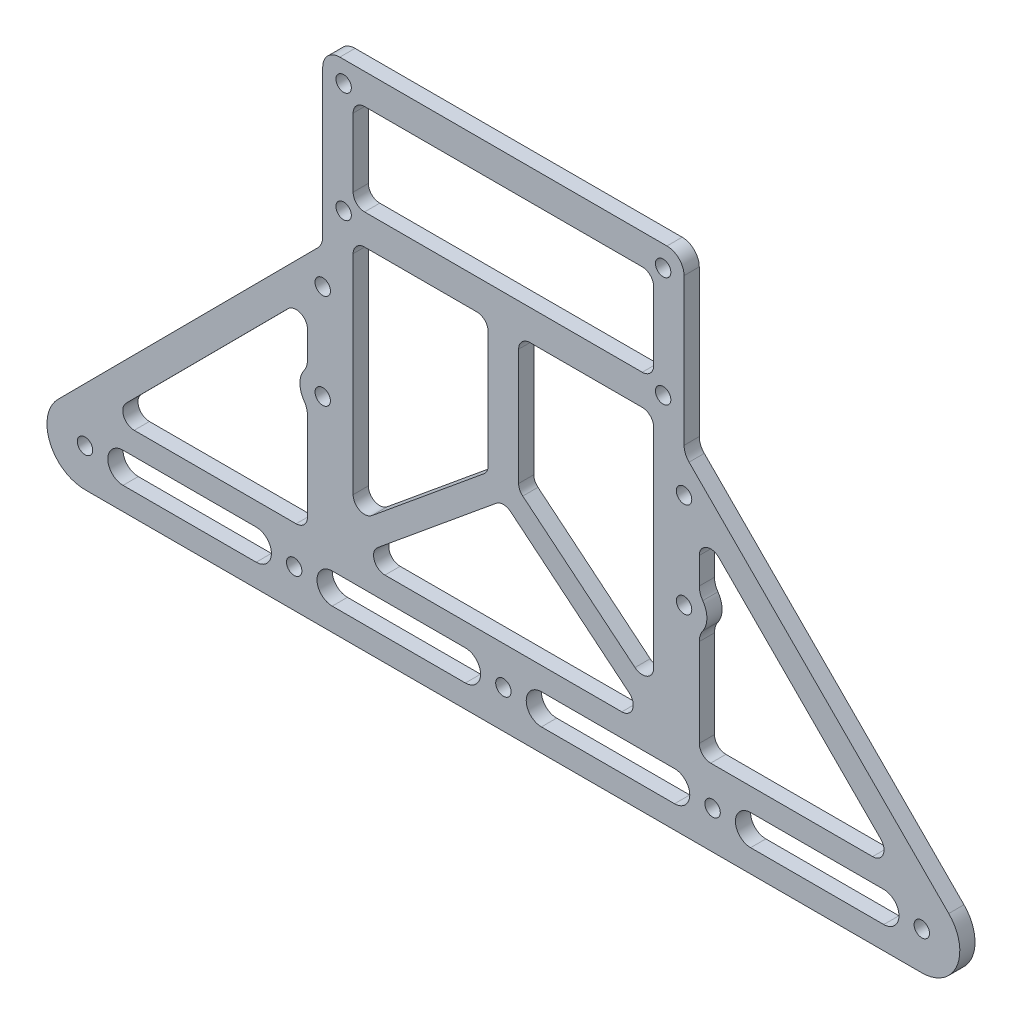
from build123d import *

# Parameters (mm, degrees)
SKETCH_1_W          = 95
SKETCH_1_H          = 40
SKETCH_1_R          = 2.025
EXTRUDE_1_DEPTH     = 4
FILLET_1_R          = 4.5
SKETCH_2_W          = 79
SKETCH_2_H          = 24
CUT_EXTRUDE_1_DEPTH = 10
FILLET_2_R          = 3
SKETCH_3_R          = 2.025
CUT_EXTRUDE_2_DEPTH = 10
SKETCH_4_R          = 6
SKETCH_4_R_2        = 2.025
EXTRUDE_2_DEPTH     = 4
FILLET_3_R          = 5


with BuildPart() as part:
    # 草图1 → 凸台-拉伸1 (new body)
    with BuildSketch(Plane.XY):
        Rectangle(SKETCH_1_W, SKETCH_1_H)
        with Locations((-42, -14.5)):
            Circle(SKETCH_1_R, mode=Mode.SUBTRACT)
        with Locations((42, -14.5)):
            Circle(SKETCH_1_R, mode=Mode.SUBTRACT)
        with Locations((42, 14.5)):
            Circle(SKETCH_1_R, mode=Mode.SUBTRACT)
        with Locations((-42, 14.5)):
            Circle(SKETCH_1_R, mode=Mode.SUBTRACT)
        with BuildLine():
            Line((47.5, -20), (-47.5, -20))
            Line((-47.5, -20), (-47.5, -25))
            Line((-47.5, -25), (-117.089181798, -94.947092696))
            ThreePointArc((-117.089181798, -94.947092696), (-113.838679914, -92.766120181), (-110, -92))
            Line((-110, -92), (110, -92))
            ThreePointArc((110, -92), (113.838679914, -92.766120181), (117.089181798, -94.947092696))
            Line((117.089181798, -94.947092696), (47.5, -25))
            Line((47.5, -25), (47.5, -20))
        make_face()
        with BuildLine():
            Line((110, -92), (-110, -92))
            ThreePointArc((-110, -92), (-120, -102), (-110, -112))
            Line((-110, -112), (110, -112))
            ThreePointArc((110, -112), (120, -102), (110, -92))
        make_face()
        with Locations((110, -102)):
            Circle(SKETCH_1_R, mode=Mode.SUBTRACT)
        with Locations((55, -102)):
            Circle(SKETCH_1_R, mode=Mode.SUBTRACT)
        with Locations((0, -102)):
            Circle(SKETCH_1_R, mode=Mode.SUBTRACT)
        with Locations((-55, -102)):
            Circle(SKETCH_1_R, mode=Mode.SUBTRACT)
        with Locations((-110, -102)):
            Circle(SKETCH_1_R, mode=Mode.SUBTRACT)
    extrude(amount=EXTRUDE_1_DEPTH)

    # 圆角1
    fillet_1_edges = [part.edges().sort_by_distance(p)[0] for p in [
        (-47.5, -25, 2),
        (-47.5, 20, 2),
        (47.5, 20, 2),
        (47.5, -25, 2),
    ]]
    fillet(fillet_1_edges, radius=FILLET_1_R)

    # 草图2 → 切除-拉伸1 (cut)
    with BuildSketch(Plane.XY.offset(4)):
        Rectangle(SKETCH_2_W, SKETCH_2_H)
        Polygon((-39.5, -84.228054643), (-39.5, -20), (-4, -20), (-4, -55), align=None)
        Polygon((4, -55), (39.5, -84.228054643), (39.5, -20), (4, -20), align=None)
        Polygon((39.5, -92), (0, -59.478643425), (0, -92), align=None)
        Polygon((0, -92), (0, -59.478643425), (-39.5, -92), align=None)
        Polygon((51.5, -92), (51.5, -38.945557904), (104.282968869, -92), align=None)
        Polygon((-104.282968869, -92), (-51.5, -92), (-51.5, -38.945557904), align=None)
        with BuildLine():
            Line((-100, -106), (-65, -106))
            ThreePointArc((-65, -106), (-61, -102), (-65, -98))
            Line((-65, -98), (-100, -98))
            ThreePointArc((-100, -98), (-104, -102), (-100, -106))
        make_face()
        with BuildLine():
            Line((-45, -106), (-10, -106))
            ThreePointArc((-10, -106), (-6, -102), (-10, -98))
            Line((-10, -98), (-45, -98))
            ThreePointArc((-45, -98), (-49, -102), (-45, -106))
        make_face()
        with BuildLine():
            Line((10, -106), (45, -106))
            ThreePointArc((45, -106), (49, -102), (45, -98))
            Line((45, -98), (10, -98))
            ThreePointArc((10, -98), (6, -102), (10, -106))
        make_face()
        with BuildLine():
            Line((65, -106), (100, -106))
            ThreePointArc((100, -106), (104, -102), (100, -98))
            Line((100, -98), (65, -98))
            ThreePointArc((65, -98), (61, -102), (65, -106))
        make_face()
    extrude(amount=-CUT_EXTRUDE_1_DEPTH, mode=Mode.SUBTRACT)

    # 圆角2
    fillet_2_edges = [part.edges().sort_by_distance(p)[0] for p in [
        (39.5, -12, 2),
        (-39.5, -12, 2),
        (-39.5, 12, 2),
        (39.5, 12, 2),
        (51.5, -92, 2),
        (51.5, -38.945557904, 2),
        (104.282968869, -92, 2),
        (0, -59.478643425, 2),
        (39.5, -92, 2),
        (-39.5, -92, 2),
        (39.5, -84.228054643, 2),
        (4, -55, 2),
        (4, -20, 2),
        (39.5, -20, 2),
        (-39.5, -84.228054643, 2),
        (-39.5, -20, 2),
        (-4, -20, 2),
        (-4, -55, 2),
        (-51.5, -92, 2),
        (-104.282968869, -92, 2),
        (-51.5, -38.945557904, 2),
    ]]
    fillet(fillet_2_edges, radius=FILLET_2_R)

    # 草图3 → 切除-拉伸2 (cut)
    with BuildSketch(Plane.XY.offset(4)):
        with Locations((-47.5, -34.5)):
            Circle(SKETCH_3_R)
        with Locations((-47.5, -59.5)):
            Circle(SKETCH_3_R)
        with Locations((47.5, -34.5)):
            Circle(SKETCH_3_R)
        with Locations((47.5, -59.5)):
            Circle(SKETCH_3_R)
    extrude(amount=-CUT_EXTRUDE_2_DEPTH, mode=Mode.SUBTRACT)

    # 草图4 → 凸台-拉伸2 (add)
    with BuildSketch(Plane.XY.offset(4)):
        with Locations((-47.5, -59.5)):
            Circle(SKETCH_4_R)
        with Locations((-47.5, -59.5)):
            Circle(SKETCH_4_R_2, mode=Mode.SUBTRACT)
        with Locations((47.5, -59.5)):
            Circle(SKETCH_4_R)
        with Locations((47.5, -59.5)):
            Circle(SKETCH_4_R_2, mode=Mode.SUBTRACT)
    extrude(amount=-EXTRUDE_2_DEPTH)

    # 圆角3
    fillet_3_edges = [part.edges().sort_by_distance(p)[0] for p in [
        (-51.5, -63.972135955, 2),
        (-51.5, -55.027864045, 2),
        (51.5, -63.972135955, 2),
        (51.5, -55.027864045, 2),
    ]]
    fillet(fillet_3_edges, radius=FILLET_3_R)


solid = part.part
